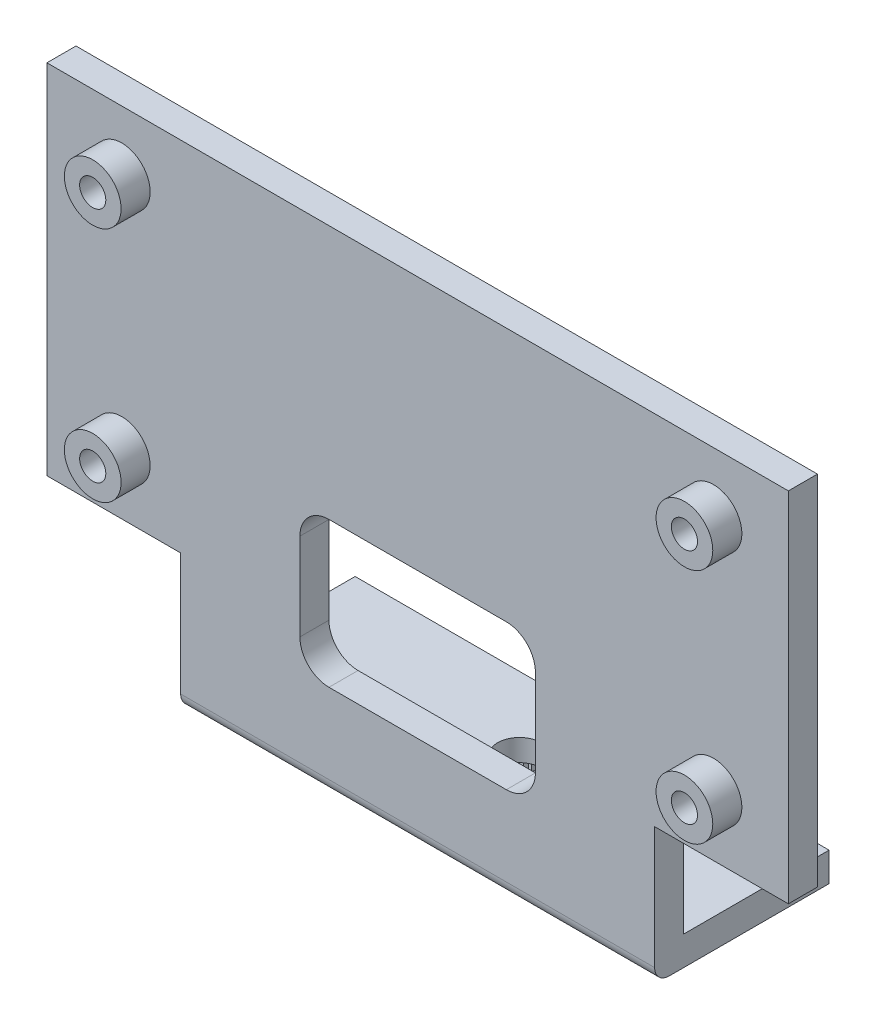
from build123d import *

# Parameters (mm, degrees)
SKETCH1_W               = 51
SKETCH1_H               = 12
BRACKET_SIZE_DEPTH      = 34
SKETCH2_W               = 10
SKETCH2_H               = 32
SIDE_PROFILE_DEPTH      = 45.161634934
SIDE_PROFILE_DEPTH_BACK = 45.161634934
FILLET1_R               = 1
SKETCH3_W               = 9.2
SKETCH3_H               = 9.4
BASE_TRIM_DEPTH         = 45.161634934
WIRE_REILEF_HOLE_DEPTH  = 45.161634934
SKETCH5_R               = 1.95
SPACER_DEPTH            = 2
M1_6_CLEARANCE_HOLE1_D  = 1.8
SKETCH8_R               = 3.4
SERVO_SPACER_DEPTH      = 3
SPLINE_TOOTH_DEPTH      = 3.5
SPLINE_COUNT            = 36
M2_CLEARANCE_HOLE1_D    = 3


with BuildPart() as part:
    # Sketch1 → Bracket Size (new body)
    with BuildSketch(Plane(origin=(0, 0, 0), x_dir=(1, 0, 0), z_dir=(0, 1, 0))):
        with Locations((0, 6)):
            Rectangle(SKETCH1_W, SKETCH1_H)
    extrude(amount=BRACKET_SIZE_DEPTH)

    # Sketch2 → Side Profile (cut, two sides)
    with BuildSketch(Plane(origin=(0, 0, 0), x_dir=(0, 0, -1), z_dir=(1, 0, 0))) as side_profile_sk:
        with Locations((7, 18)):
            Rectangle(SKETCH2_W, SKETCH2_H)
    extrude(amount=SIDE_PROFILE_DEPTH, mode=Mode.SUBTRACT)
    extrude(side_profile_sk.sketch, amount=-SIDE_PROFILE_DEPTH_BACK, mode=Mode.SUBTRACT)

    # Fillet1
    fillet1_edges = [part.edges().sort_by_distance(p)[0] for p in [
        (0, 0, 0),
    ]]
    fillet(fillet1_edges, radius=FILLET1_R)

    # Sketch3 → Base Trim (cut, through all)
    with BuildSketch(Plane.XY):
        with Locations((20.9, 4.7)):
            Rectangle(SKETCH3_W, SKETCH3_H)
        with Locations((-20.9, 4.7)):
            Rectangle(SKETCH3_W, SKETCH3_H)
    extrude(amount=-BASE_TRIM_DEPTH, mode=Mode.SUBTRACT)

    # Sketch4 → Wire Reilef Hole (cut, through all)
    with BuildSketch(Plane.XY):
        with BuildLine():
            Line((-6.1, 16.5), (6.1, 16.5))
            ThreePointArc((6.1, 16.5), (7.514213562, 15.914213562), (8.1, 14.5))
            Line((8.1, 14.5), (8.1, 8.5))
            ThreePointArc((8.1, 8.5), (7.514213562, 7.085786438), (6.1, 6.5))
            Line((6.1, 6.5), (-6.1, 6.5))
            ThreePointArc((-6.1, 6.5), (-7.514213562, 7.085786438), (-8.1, 8.5))
            Line((-8.1, 8.5), (-8.1, 14.5))
            ThreePointArc((-8.1, 14.5), (-7.514213562, 15.914213562), (-6.1, 16.5))
        make_face()
    extrude(amount=-WIRE_REILEF_HOLE_DEPTH, mode=Mode.SUBTRACT)

    # Sketch5 → Spacer (add)
    with BuildSketch(Plane.XY):
        with Locations(Location((-20.35, 29.85, 0), (0, 0, 180))):
            Circle(SKETCH5_R)
    spacer = extrude(amount=SPACER_DEPTH)

    # M1.6 Clearance Hole1 (through all)
    with Locations(Plane.XY.offset(2)):
        with Locations((-20.35, 29.85)):
            m1_6_clearance_hole1 = Hole(M1_6_CLEARANCE_HOLE1_D / 2)

    # Spacer Pattern: Spacer, M1.6 Clearance Hole1 at 3 more places
    with Locations((0, -16.3, 0), (40.7, -16.3, 0), (40.7, 0, 0)):
        add(spacer)
        add(m1_6_clearance_hole1, mode=Mode.SUBTRACT)

    # Sketch8 → Servo Spacer (add)
    with BuildSketch(Plane(origin=(0, 0, 0), x_dir=(1, 0, 0), z_dir=(0, 1, 0))):
        with Locations(Location((0, 7, 0), (0, 0, 270))):
            Circle(SKETCH8_R)
    extrude(amount=-SERVO_SPACER_DEPTH)

    # Sketch9 → Spline Tooth (cut)
    with BuildSketch(Plane.XZ.offset(3)):
        Polygon((0.39070839, -4.78418261), (0.217889353, -4.509513302), (0, -4.750000055), (0, -7), align=None)
    spline_tooth = extrude(amount=-SPLINE_TOOTH_DEPTH, mode=Mode.SUBTRACT)

    # Spline: Spline Tooth ×36 about axis
    spline_axis = Axis((0, 0, -7), (0, 1, 0))
    for i in range(1, SPLINE_COUNT):
        add(spline_tooth.rotate(spline_axis, i * 360 / SPLINE_COUNT), mode=Mode.SUBTRACT)

    # M2 Clearance Hole1 (through all)
    with Locations(Plane.XZ):
        with Locations((0, -7)):
            Hole(M2_CLEARANCE_HOLE1_D / 2)


solid = part.part
